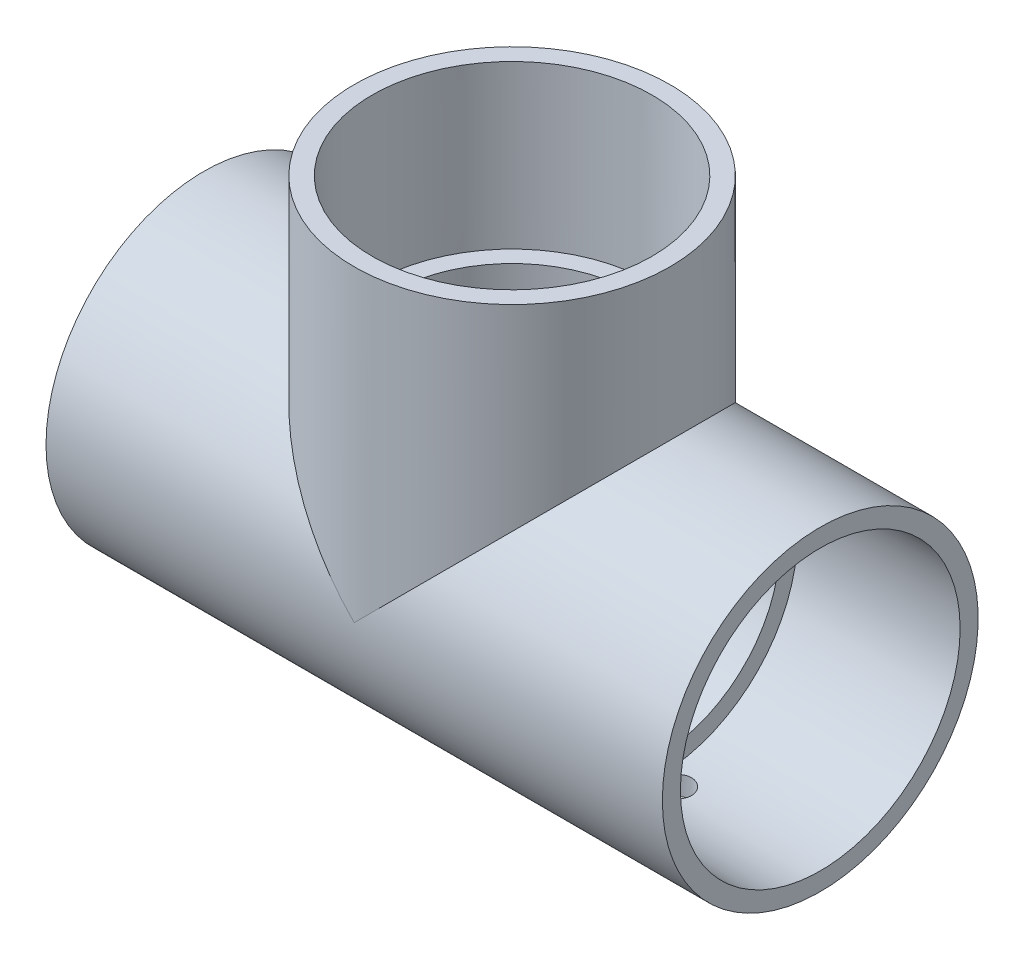
from build123d import *

# Parameters (mm, degrees)
SKETCH4_R           = 34.2265
BOSS_EXTRUDE1_DEPTH = 63.5
SKETCH5_R           = 34.2265
BOSS_EXTRUDE2_DEPTH = 31.75
CUT_EXTRUDE1_REACH  = 36.227
SKETCH8_R           = 3.175


with BuildPart() as part:
    # Sketch1 → Revolve1 (revolve)
    with BuildSketch(Plane.XY):
        Polygon((-66.802, -34.2265), (-31.75, -34.2265), (-31.75, -30.0863), (-66.802, -30.3149), align=None)
        Polygon((66.802, -30.3149), (31.75, -30.0863), (31.75, -34.2265), (66.802, -34.2265), align=None)
    revolve(axis=Axis((-66.802, 0, 0), (1, 0, 0)))



with BuildPart() as body_2:
    # Sketch2 → Revolve2 (revolve)
    with BuildSketch(Plane.XY):
        Polygon((30.3149, 66.802), (30.0863, 31.75), (34.2265, 31.75), (34.2265, 66.802), align=None)
    revolve(axis=Axis((0, 0, 0), (0, 1, 0)))


with BuildPart() as part_1:
    add(part.part)

    add(body_2.part)  # Boss-Extrude1 merges body 2
    # Sketch4 → Boss-Extrude1 (add)
    with BuildSketch(Plane(origin=(-31.75, 0, 0), x_dir=(0, 0, -1), z_dir=(1, 0, 0))):
        Circle(SKETCH4_R)
    extrude(amount=BOSS_EXTRUDE1_DEPTH)

    # Sketch5 → Boss-Extrude2 (add)
    with BuildSketch(Plane.XZ.offset(-31.75)):
        Circle(SKETCH5_R)
    extrude(amount=BOSS_EXTRUDE2_DEPTH)

    # Sketch6 → Cut-Revolve1 (revolve, cut)
    with BuildSketch(Plane.XY):
        Polygon((-66.802, -30.3149), (-31.75, -30.0863), (-31.75, -26.2509), (31.75, -26.2509), (31.75, -30.0863), (66.802, -30.3149), (66.802, 0), (-66.802, 0), align=None)
    revolve(axis=Axis((66.802, 0, 0), (-1, 0, 0)), mode=Mode.SUBTRACT)

    # Sketch7 → Cut-Revolve2 (revolve, cut)
    with BuildSketch(Plane.XY):
        Polygon((30.3149, 66.802), (30.0863, 31.75), (26.2509, 31.75), (26.2509, 0), (0, 0), (0, 66.802), align=None)
    revolve(axis=Axis((0, 0, 0), (0, 1, 0)), mode=Mode.SUBTRACT)

    # Sketch8 → Cut-Extrude1 (cut, up to next)
    with BuildSketch(Plane(origin=(0, 0, 0), x_dir=(1, 0, 0), z_dir=(0, 1, 0)), mode=Mode.PRIVATE) as cut_extrude1_sk1:
        with Locations((35.71875, 0)):
            Circle(SKETCH8_R)
    cut_extrude1_tool1 = extrude(cut_extrude1_sk1.sketch, amount=-CUT_EXTRUDE1_REACH, mode=Mode.PRIVATE) & part_1.part
    add(cut_extrude1_tool1.solids().sort_by_distance((35.71875, 0, 0))[0], mode=Mode.SUBTRACT)
    # Sketch8 → Cut-Extrude1 (cut, up to next)
    with BuildSketch(Plane(origin=(0, 0, 0), x_dir=(1, 0, 0), z_dir=(0, 1, 0)), mode=Mode.PRIVATE) as cut_extrude1_sk2:
        with Locations((-35.71875, 0)):
            Circle(SKETCH8_R)
    cut_extrude1_tool2 = extrude(cut_extrude1_sk2.sketch, amount=-CUT_EXTRUDE1_REACH, mode=Mode.PRIVATE) & part_1.part
    add(cut_extrude1_tool2.solids().sort_by_distance((-35.71875, 0, 0))[0], mode=Mode.SUBTRACT)


solid = part_1.part
